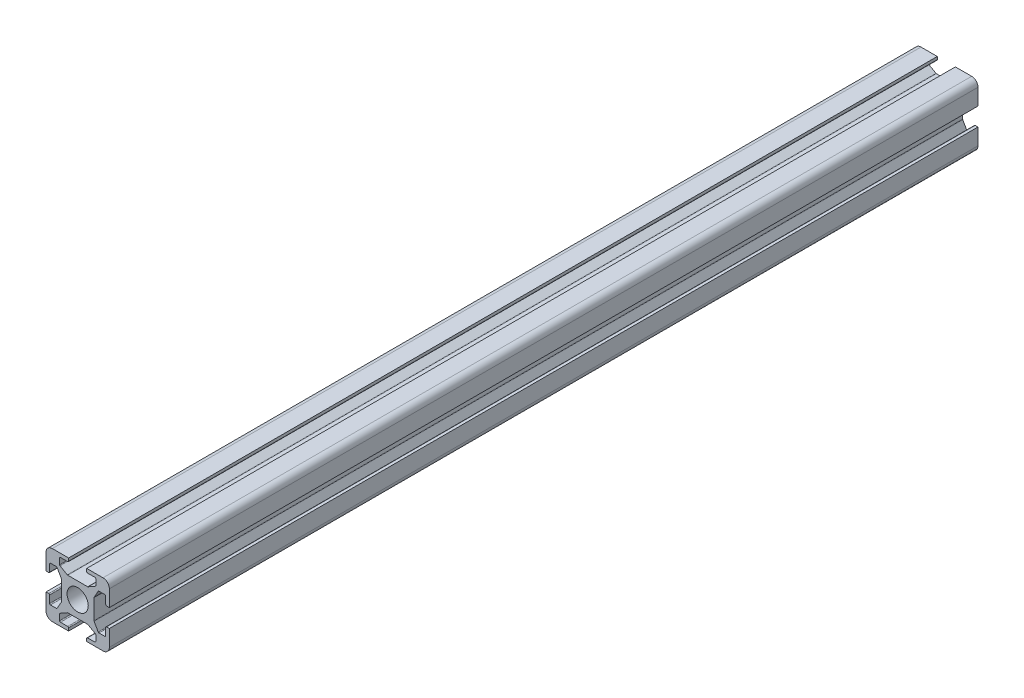
from build123d import *

# Parameters (mm, degrees)
CROQUIS1_R              = 5.85
SALIENTE_EXTRUIR1_DEPTH = 480


with BuildPart() as part:
    # Croquis1 → Saliente-Extruir1 (new body)
    with BuildSketch(Plane.XY):
        with BuildLine():
            Line((-17.5, -5), (-16, -5))
            ThreePointArc((-16, -5), (-15.646446609, -5.146446609), (-15.5, -5.5))
            Line((-15.5, -5.5), (-15.5, -9.5))
            ThreePointArc((-15.5, -9.5), (-15.353553391, -9.853553391), (-15, -10))
            Line((-15, -10), (-11.790147321, -10))
            ThreePointArc((-11.790147321, -10), (-11.539192936, -9.932460283), (-11.356036103, -9.748087586))
            Line((-11.356036103, -9.748087586), (-9.065888782, -5.740718013))
            ThreePointArc((-9.065888782, -5.740718013), (-9.016752854, -5.620974478), (-9, -5.492630427))
            Line((-9, -5.492630427), (-9, 5.492630427))
            ThreePointArc((-9, 5.492630427), (-9.016752854, 5.620974478), (-9.065888782, 5.740718013))
            Line((-9.065888782, 5.740718013), (-11.356036103, 9.748087586))
            ThreePointArc((-11.356036103, 9.748087586), (-11.539192936, 9.932460283), (-11.790147321, 10))
            Line((-11.790147321, 10), (-15, 10))
            ThreePointArc((-15, 10), (-15.353553391, 9.853553391), (-15.5, 9.5))
            Line((-15.5, 9.5), (-15.5, 5.5))
            ThreePointArc((-15.5, 5.5), (-15.646446609, 5.146446609), (-16, 5))
            Line((-16, 5), (-17.5, 5))
            Line((-17.5, 5), (-17.5, 14))
            ThreePointArc((-17.5, 14), (-16.474873734, 16.474873734), (-14, 17.5))
            Line((-14, 17.5), (-5, 17.5))
            Line((-5, 17.5), (-5, 16))
            ThreePointArc((-5, 16), (-5.146446609, 15.646446609), (-5.5, 15.5))
            Line((-5.5, 15.5), (-9.5, 15.5))
            ThreePointArc((-9.5, 15.5), (-9.853553391, 15.353553391), (-10, 15))
            Line((-10, 15), (-10, 11.790147321))
            ThreePointArc((-10, 11.790147321), (-9.932460283, 11.539192936), (-9.748087586, 11.356036103))
            Line((-9.748087586, 11.356036103), (-5.740718013, 9.065888782))
            ThreePointArc((-5.740718013, 9.065888782), (-5.620974478, 9.016752854), (-5.492630427, 9))
            Line((-5.492630427, 9), (5.492630427, 9))
            ThreePointArc((5.492630427, 9), (5.620974478, 9.016752854), (5.740718013, 9.065888782))
            Line((5.740718013, 9.065888782), (9.748087586, 11.356036103))
            ThreePointArc((9.748087586, 11.356036103), (9.932460283, 11.539192936), (10, 11.790147321))
            Line((10, 11.790147321), (10, 15))
            ThreePointArc((10, 15), (9.853553391, 15.353553391), (9.5, 15.5))
            Line((9.5, 15.5), (5.5, 15.5))
            ThreePointArc((5.5, 15.5), (5.146446609, 15.646446609), (5, 16))
            Line((5, 16), (5, 17.5))
            Line((5, 17.5), (14, 17.5))
            ThreePointArc((14, 17.5), (16.474873734, 16.474873734), (17.5, 14))
            Line((17.5, 14), (17.5, 5))
            Line((17.5, 5), (16, 5))
            ThreePointArc((16, 5), (15.646446609, 5.146446609), (15.5, 5.5))
            Line((15.5, 5.5), (15.5, 9.5))
            ThreePointArc((15.5, 9.5), (15.353553391, 9.853553391), (15, 10))
            Line((15, 10), (11.790147321, 10))
            ThreePointArc((11.790147321, 10), (11.539192936, 9.932460283), (11.356036103, 9.748087586))
            Line((11.356036103, 9.748087586), (9.065888782, 5.740718013))
            ThreePointArc((9.065888782, 5.740718013), (9.016752854, 5.620974478), (9, 5.492630427))
            Line((9, 5.492630427), (9, -5.492630427))
            ThreePointArc((9, -5.492630427), (9.016752854, -5.620974478), (9.065888782, -5.740718013))
            Line((9.065888782, -5.740718013), (11.356036103, -9.748087586))
            ThreePointArc((11.356036103, -9.748087586), (11.539192936, -9.932460283), (11.790147321, -10))
            Line((11.790147321, -10), (15, -10))
            ThreePointArc((15, -10), (15.353553391, -9.853553391), (15.5, -9.5))
            Line((15.5, -9.5), (15.5, -5.5))
            ThreePointArc((15.5, -5.5), (15.646446609, -5.146446609), (16, -5))
            Line((16, -5), (17.5, -5))
            Line((17.5, -5), (17.5, -14))
            ThreePointArc((17.5, -14), (16.474873734, -16.474873734), (14, -17.5))
            Line((14, -17.5), (5, -17.5))
            Line((5, -17.5), (5, -16))
            ThreePointArc((5, -16), (5.146446609, -15.646446609), (5.5, -15.5))
            Line((5.5, -15.5), (9.5, -15.5))
            ThreePointArc((9.5, -15.5), (9.853553391, -15.353553391), (10, -15))
            Line((10, -15), (10, -11.790147321))
            ThreePointArc((10, -11.790147321), (9.932460283, -11.539192936), (9.748087586, -11.356036103))
            Line((9.748087586, -11.356036103), (5.740718013, -9.065888782))
            ThreePointArc((5.740718013, -9.065888782), (5.620974478, -9.016752854), (5.492630427, -9))
            Line((5.492630427, -9), (-5.492630427, -9))
            ThreePointArc((-5.492630427, -9), (-5.620974478, -9.016752854), (-5.740718013, -9.065888782))
            Line((-5.740718013, -9.065888782), (-9.748087586, -11.356036103))
            ThreePointArc((-9.748087586, -11.356036103), (-9.932460283, -11.539192936), (-10, -11.790147321))
            Line((-10, -11.790147321), (-10, -15))
            ThreePointArc((-10, -15), (-9.853553391, -15.353553391), (-9.5, -15.5))
            Line((-9.5, -15.5), (-5.5, -15.5))
            ThreePointArc((-5.5, -15.5), (-5.146446609, -15.646446609), (-5, -16))
            Line((-5, -16), (-5, -17.5))
            Line((-5, -17.5), (-14, -17.5))
            ThreePointArc((-14, -17.5), (-16.474873734, -16.474873734), (-17.5, -14))
            Line((-17.5, -14), (-17.5, -5))
        make_face()
        Circle(CROQUIS1_R, mode=Mode.SUBTRACT)
    extrude(amount=SALIENTE_EXTRUIR1_DEPTH)


solid = part.part
